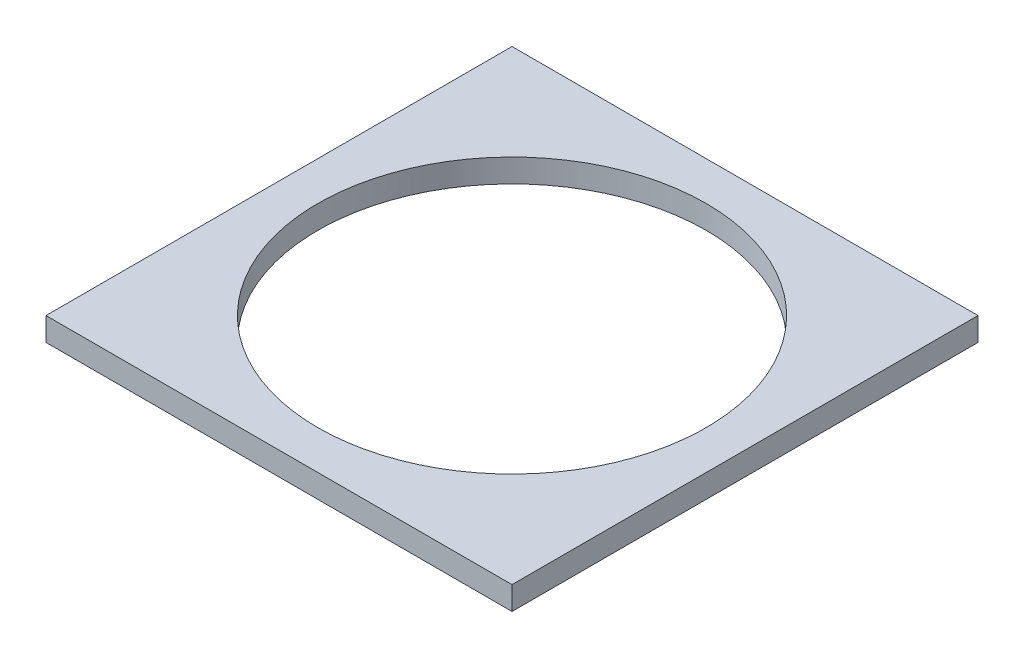
from build123d import *

# Parameters (mm, degrees)
SKETCH2_W           = 152.4
SKETCH2_H           = 152.4
SKETCH2_R           = 63.5
BOSS_EXTRUDE1_DEPTH = 7.62


with BuildPart() as part:
    # Sketch2 → Boss-Extrude1 (new body)
    with BuildSketch(Plane(origin=(0, 0, 0), x_dir=(1, 0, 0), z_dir=(0, 1, 0))):
        Rectangle(SKETCH2_W, SKETCH2_H)
        Circle(SKETCH2_R, mode=Mode.SUBTRACT)
    extrude(amount=BOSS_EXTRUDE1_DEPTH)


solid = part.part
